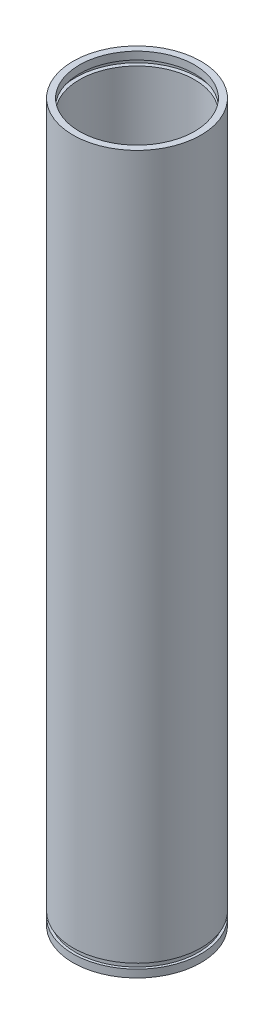
from build123d import *

# Parameters (mm, degrees)
SKETCH1_R           = 25
SKETCH1_R_2         = 22.5
BOSS_EXTRUDE1_DEPTH = 280


with BuildPart() as part:
    # Sketch1 → Boss-Extrude1 (new body)
    with BuildSketch(Plane(origin=(0, 0, 0), x_dir=(1, 0, 0), z_dir=(0, 1, 0))):
        Circle(SKETCH1_R)
        Circle(SKETCH1_R_2, mode=Mode.SUBTRACT)
    extrude(amount=BOSS_EXTRUDE1_DEPTH)

    # Sketch2 → Cut-Revolve1 (revolve, cut)
    with BuildSketch(Plane.XY):
        Polygon((24, 275), (22.5, 275), (22.157069883, 275), (22.157069883, 277), (22.5, 277), (24, 277), align=None)
        Polygon((22.5, 8), (24, 8), (24, 10), (21.749142676, 10), (21.749142676, 8), align=None)
        Polygon((25, 3), (24, 3), (24, 5), (25.376612155, 5), (25.376612155, 3), align=None)
    revolve(axis=Axis((0, 307.21500467, 0), (0, -1, 0)), mode=Mode.SUBTRACT)


solid = part.part
